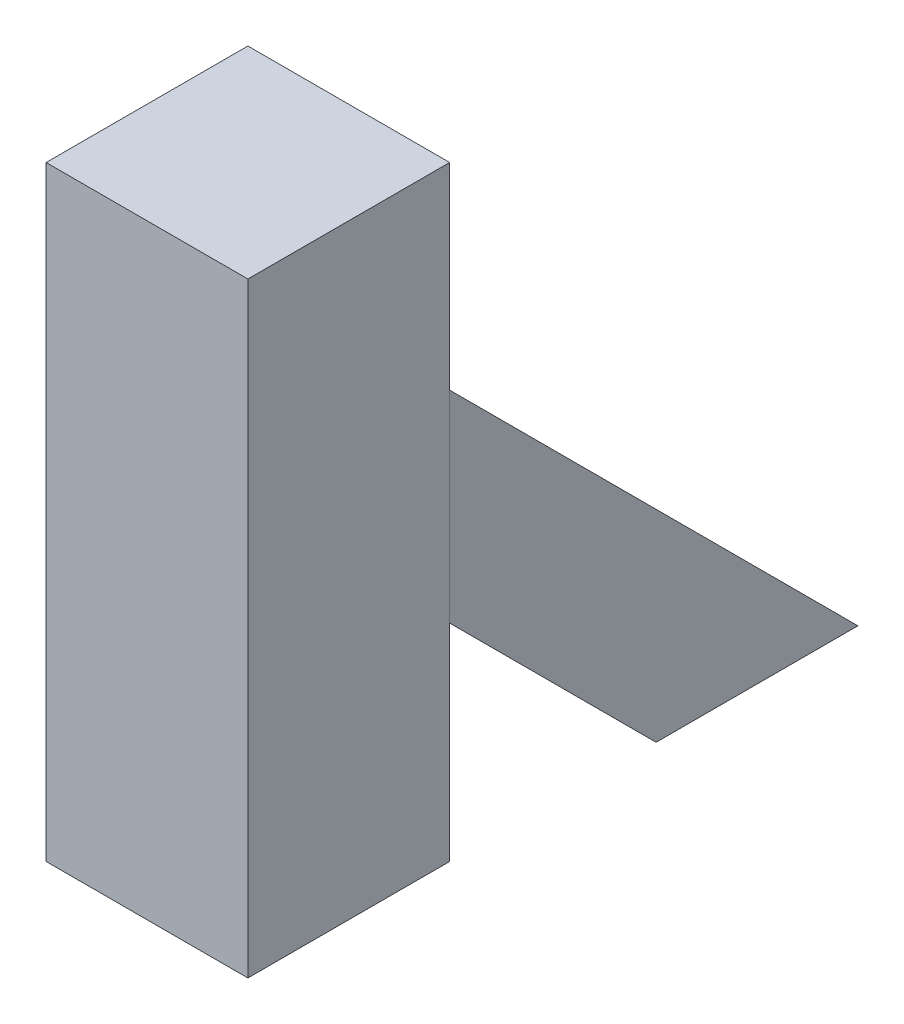
from build123d import *

# Parameters (mm, degrees)
SKETCH1_W           = 100
SKETCH1_H           = 100
BOSS_EXTRUDE1_DEPTH = 300
BOSS_EXTRUDE2_DEPTH = 100


with BuildPart() as part:
    # Sketch1 → Boss-Extrude1 (new body)
    with BuildSketch(Plane(origin=(0, 0, 0), x_dir=(1, 0, 0), z_dir=(0, 1, 0))):
        Rectangle(SKETCH1_W, SKETCH1_H)
    extrude(amount=BOSS_EXTRUDE1_DEPTH)


with BuildPart() as body_2:
    # Sketch2 → Boss-Extrude2 (new body)
    with BuildSketch(Plane(origin=(50, 0, 0), x_dir=(0, 0, -1), z_dir=(1, 0, 0))):
        Polygon((50, 202.313201964), (252.313201964, 0), (152.313201964, 0), (50, 102.313201964), align=None)
    extrude(amount=-BOSS_EXTRUDE2_DEPTH)


solid = Compound([part.part, body_2.part])
